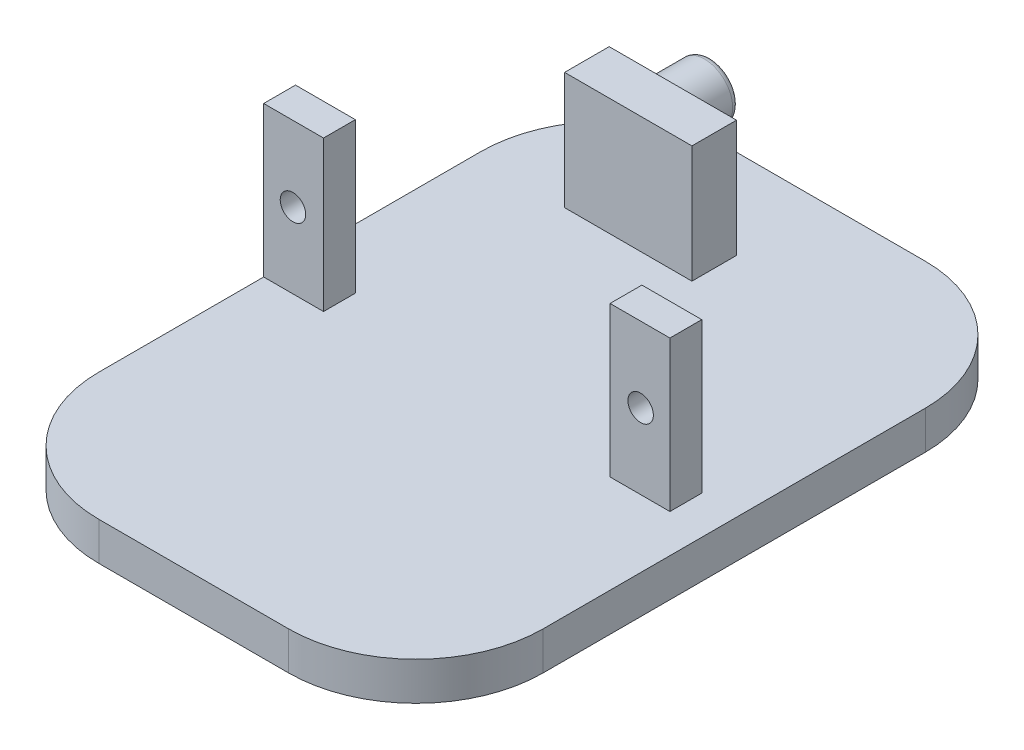
from build123d import *

# Parameters (mm, degrees)
ESQUISSE1_W             = 34.9
ESQUISSE1_H             = 3
BOSS_EXTRU_1_DEPTH      = 50
ESQUISSE2_W             = 10
ESQUISSE2_H             = 3.5
BOSS_EXTRU_2_DEPTH      = 9.2
ESQUISSE3_R             = 2.2
BOSS_EXTRU_3_DEPTH      = 4.5
CONG_1_R                = 0.5
ESQUISSE5_W             = 4.7
ESQUISSE5_H             = 2.5
BOSS_EXTRU_5_DEPTH      = 11.8
ENL_V_MAT_EXTRU_1_REACH = 29.05
ESQUISSE6_R             = 1
CONG_2_R                = 10


with BuildPart() as part:
    # Esquisse1 → Boss.-Extru.1 (new body)
    with BuildSketch(Plane.XY):
        with Locations((17.45, 1.5)):
            Rectangle(ESQUISSE1_W, ESQUISSE1_H)
    extrude(amount=BOSS_EXTRU_1_DEPTH)

    # Esquisse2 → Boss.-Extru.2 (add)
    with BuildSketch(Plane(origin=(0, 3, 0), x_dir=(1, 0, 0), z_dir=(0, 1, 0))):
        with Locations((12.1, -8.77)):
            Rectangle(ESQUISSE2_W, ESQUISSE2_H)
    extrude(amount=BOSS_EXTRU_2_DEPTH)

    # Esquisse3 → Boss.-Extru.3 (add)
    with BuildSketch(Plane(origin=(0, 0, 7.02), x_dir=(-1, 0, 0), z_dir=(0, 0, -1))):
        with Locations((-10.6, 8.9)):
            Circle(ESQUISSE3_R)
    extrude(amount=BOSS_EXTRU_3_DEPTH)

    # Congé1
    cong_1_edges = [part.edges().sort_by_distance(p)[0] for p in [
        (12.8, 8.9, 2.52),
    ]]
    fillet(cong_1_edges, radius=CONG_1_R)

    # Esquisse5 → Boss.-Extru.5 (add)
    with BuildSketch(Plane(origin=(0, 3, 0), x_dir=(1, 0, 0), z_dir=(0, 1, 0))):
        with Locations((29.55, -25.8)):
            Rectangle(ESQUISSE5_W, ESQUISSE5_H)
        with Locations((2.35, -25.8)):
            Rectangle(ESQUISSE5_W, ESQUISSE5_H)
    extrude(amount=BOSS_EXTRU_5_DEPTH)

    # Esquisse6 → Enlèv. mat.-Extru.1 (cut, up to next)
    with BuildSketch(Plane.XY.offset(27.05), mode=Mode.PRIVATE) as enl_v_mat_extru_1_sk1:
        with Locations((29.6, 8.9)):
            Circle(ESQUISSE6_R)
    enl_v_mat_extru_1_tool1 = extrude(enl_v_mat_extru_1_sk1.sketch, amount=-ENL_V_MAT_EXTRU_1_REACH, mode=Mode.PRIVATE) & part.part
    add(enl_v_mat_extru_1_tool1.solids().sort_by_distance((29.6, 8.9, 27.05))[0], mode=Mode.SUBTRACT)
    # Esquisse6 → Enlèv. mat.-Extru.1 (cut, up to next)
    with BuildSketch(Plane.XY.offset(27.05), mode=Mode.PRIVATE) as enl_v_mat_extru_1_sk2:
        with Locations((2.3, 8.9)):
            Circle(ESQUISSE6_R)
    enl_v_mat_extru_1_tool2 = extrude(enl_v_mat_extru_1_sk2.sketch, amount=-ENL_V_MAT_EXTRU_1_REACH, mode=Mode.PRIVATE) & part.part
    add(enl_v_mat_extru_1_tool2.solids().sort_by_distance((2.3, 8.9, 27.05))[0], mode=Mode.SUBTRACT)

    # Congé2
    cong_2_edges = [part.edges().sort_by_distance(p)[0] for p in [
        (34.9, 1.5, 50),
        (0, 1.5, 50),
        (34.9, 1.5, 0),
        (0, 1.5, 0),
    ]]
    fillet(cong_2_edges, radius=CONG_2_R)


solid = part.part
